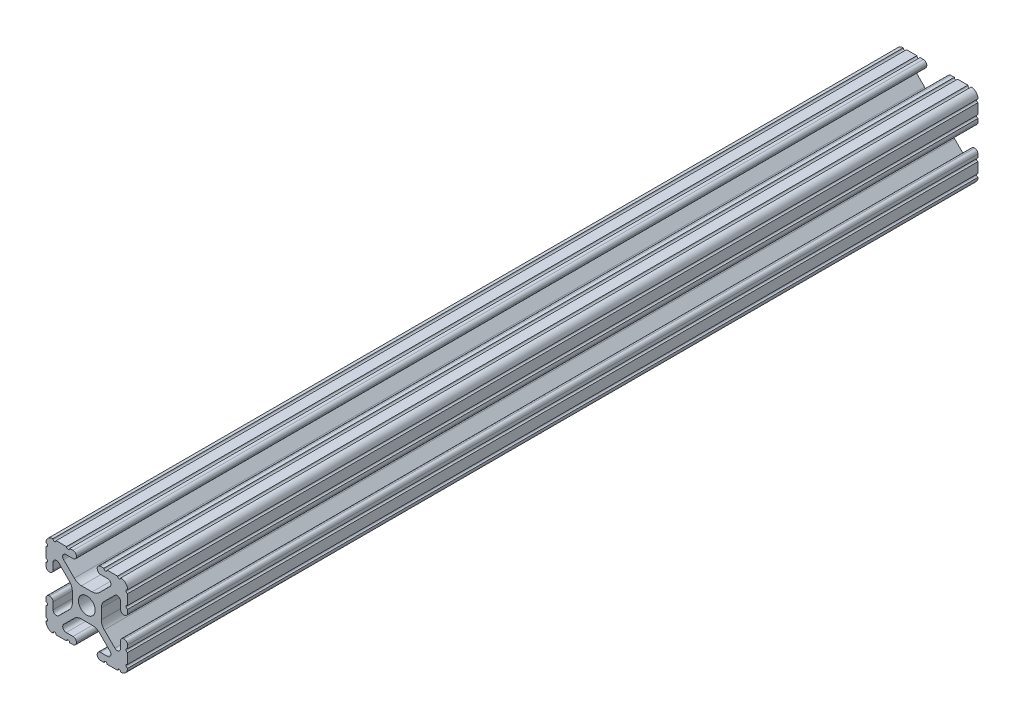
from build123d import *

# Parameters (mm, degrees)
SKETCH1_R               = 2.6035
BOSS_EXTRUDE1_DEPTH     = 457.2
CUT_EXTRUDE2_DEPTH      = 4.318
CUT_EXTRUDE2_DEPTH_BACK = 26.924
SKETCH5_W               = 400.863196081
SKETCH5_H               = 43.327238712
CUT_EXTRUDE3_DEPTH      = 26.4


with BuildPart() as part:
    # Sketch1 → Boss-Extrude1 (new body, symmetric)
    with BuildSketch(Plane.XY):
        with BuildLine():
            Line((-7.179650497, -8.645192506), (-3.952270251, -5.423690499))
            ThreePointArc((-3.952270251, -5.423690499), (-2.922936451, -4.736929036), (-1.709253557, -4.4958))
            Line((-1.709253557, -4.4958), (1.709253557, -4.4958))
            ThreePointArc((1.709253557, -4.4958), (2.922936451, -4.736929036), (3.952270251, -5.423690499))
            Line((3.952270251, -5.423690499), (7.179650497, -8.645192506))
            ThreePointArc((7.179650497, -8.645192506), (7.41473083, -9.822813117), (6.416408329, -10.4902))
            Line((6.416408329, -10.4902), (4.287512407, -10.4902))
            ThreePointArc((4.287512407, -10.4902), (3.54574862, -10.79744862), (3.2385, -11.539212407))
            Line((3.2385, -11.539212407), (3.2385, -11.650987593))
            ThreePointArc((3.2385, -11.650987593), (3.54574862, -12.39275138), (4.287512407, -12.7))
            Line((4.287512407, -12.7), (5.317126718, -12.7))
            ThreePointArc((5.317126718, -12.7), (5.825126718, -12.192), (6.333126718, -12.7))
            Line((6.333126718, -12.7), (9.550443118, -12.7))
            ThreePointArc((9.550443118, -12.7), (10.058366869, -12.192000006), (10.566443095, -12.699847501))
            ThreePointArc((10.566443095, -12.699847501), (12.082537762, -12.08250727), (12.699846982, -10.566399977))
            ThreePointArc((12.699846982, -10.566399977), (12.192000006, -10.058323491), (12.7, -9.5504))
            Line((12.7, -9.5504), (12.7, -6.3330836))
            ThreePointArc((12.7, -6.3330836), (12.192, -5.8250836), (12.7, -5.3170836))
            Line((12.7, -5.3170836), (12.7, -4.287469289))
            ThreePointArc((12.7, -4.287469289), (12.39275138, -3.545705502), (11.650987593, -3.238456882))
            Line((11.650987593, -3.238456882), (11.539212407, -3.238456882))
            ThreePointArc((11.539212407, -3.238456882), (10.79744862, -3.545705502), (10.4902, -4.287469289))
            Line((10.4902, -4.287469289), (10.4902, -6.402089023))
            ThreePointArc((10.4902, -6.402089023), (9.856505071, -7.351067942), (8.737131347, -7.129408934))
            Line((8.737131347, -7.129408934), (5.441005833, -3.840816462))
            ThreePointArc((5.441005833, -3.840816462), (4.750877967, -2.809883091), (4.5085, -1.593185507))
            Line((4.5085, -1.593185507), (4.5085, 1.593185507))
            ThreePointArc((4.5085, 1.593185507), (4.750877967, 2.809883091), (5.441005833, 3.840816462))
            Line((5.441005833, 3.840816462), (8.737131347, 7.129408934))
            ThreePointArc((8.737131347, 7.129408934), (9.856505071, 7.351067942), (10.4902, 6.402089023))
            Line((10.4902, 6.402089023), (10.4902, 4.287469289))
            ThreePointArc((10.4902, 4.287469289), (10.79744862, 3.545705502), (11.539212407, 3.238456882))
            Line((11.539212407, 3.238456882), (11.650987593, 3.238456882))
            ThreePointArc((11.650987593, 3.238456882), (12.39275138, 3.545705502), (12.7, 4.287469289))
            Line((12.7, 4.287469289), (12.7, 5.3170836))
            ThreePointArc((12.7, 5.3170836), (12.192, 5.8250836), (12.7, 6.3330836))
            Line((12.7, 6.3330836), (12.7, 9.5504))
            ThreePointArc((12.7, 9.5504), (12.192000006, 10.058323491), (12.699846982, 10.566399977))
            ThreePointArc((12.699846982, 10.566399977), (12.082537762, 12.08250727), (10.566443095, 12.699847501))
            ThreePointArc((10.566443095, 12.699847501), (10.058366869, 12.192000006), (9.550443118, 12.7))
            Line((9.550443118, 12.7), (6.333126718, 12.7))
            ThreePointArc((6.333126718, 12.7), (5.825126718, 12.192), (5.317126718, 12.7))
            Line((5.317126718, 12.7), (4.287512407, 12.7))
            ThreePointArc((4.287512407, 12.7), (3.54574862, 12.39275138), (3.2385, 11.650987593))
            Line((3.2385, 11.650987593), (3.2385, 11.539212407))
            ThreePointArc((3.2385, 11.539212407), (3.54574862, 10.79744862), (4.287512407, 10.4902))
            Line((4.287512407, 10.4902), (6.476788598, 10.4902))
            ThreePointArc((6.476788598, 10.4902), (7.432222385, 9.85140422), (7.207036008, 8.724370562))
            Line((7.207036008, 8.724370562), (3.898272566, 5.423169045))
            ThreePointArc((3.898272566, 5.423169045), (2.869120213, 4.736787962), (1.655778399, 4.4958))
            Line((1.655778399, 4.4958), (-1.655778399, 4.4958))
            ThreePointArc((-1.655778399, 4.4958), (-2.869120213, 4.736787962), (-3.898272566, 5.423169045))
            Line((-3.898272566, 5.423169045), (-7.207036008, 8.724370562))
            ThreePointArc((-7.207036008, 8.724370562), (-7.432222385, 9.85140422), (-6.476788598, 10.4902))
            Line((-6.476788598, 10.4902), (-4.287512407, 10.4902))
            ThreePointArc((-4.287512407, 10.4902), (-3.54574862, 10.79744862), (-3.2385, 11.539212407))
            Line((-3.2385, 11.539212407), (-3.2385, 11.650987593))
            ThreePointArc((-3.2385, 11.650987593), (-3.54574862, 12.39275138), (-4.287512407, 12.7))
            Line((-4.287512407, 12.7), (-5.317126718, 12.7))
            ThreePointArc((-5.317126718, 12.7), (-5.825126718, 12.192), (-6.333126718, 12.7))
            Line((-6.333126718, 12.7), (-9.550443118, 12.7))
            ThreePointArc((-9.550443118, 12.7), (-10.058366869, 12.192000006), (-10.566443095, 12.699847501))
            ThreePointArc((-10.566443095, 12.699847501), (-12.082537762, 12.08250727), (-12.699846982, 10.566399977))
            ThreePointArc((-12.699846982, 10.566399977), (-12.192000006, 10.058323491), (-12.7, 9.5504))
            Line((-12.7, 9.5504), (-12.7, 6.3330836))
            ThreePointArc((-12.7, 6.3330836), (-12.192, 5.8250836), (-12.7, 5.3170836))
            Line((-12.7, 5.3170836), (-12.7, 4.287469289))
            ThreePointArc((-12.7, 4.287469289), (-12.39275138, 3.545705502), (-11.650987593, 3.238456882))
            Line((-11.650987593, 3.238456882), (-11.539212407, 3.238456882))
            ThreePointArc((-11.539212407, 3.238456882), (-10.79744862, 3.545705502), (-10.4902, 4.287469289))
            Line((-10.4902, 4.287469289), (-10.4902, 6.402089023))
            ThreePointArc((-10.4902, 6.402089023), (-9.856505071, 7.351067942), (-8.737131347, 7.129408934))
            Line((-8.737131347, 7.129408934), (-5.441005833, 3.840816462))
            ThreePointArc((-5.441005833, 3.840816462), (-4.750877967, 2.809883091), (-4.5085, 1.593185507))
            Line((-4.5085, 1.593185507), (-4.5085, -1.593185507))
            ThreePointArc((-4.5085, -1.593185507), (-4.750877967, -2.809883091), (-5.441005833, -3.840816462))
            Line((-5.441005833, -3.840816462), (-8.737131347, -7.129408934))
            ThreePointArc((-8.737131347, -7.129408934), (-9.856505071, -7.351067942), (-10.4902, -6.402089023))
            Line((-10.4902, -6.402089023), (-10.4902, -4.287469289))
            ThreePointArc((-10.4902, -4.287469289), (-10.79744862, -3.545705502), (-11.539212407, -3.238456882))
            Line((-11.539212407, -3.238456882), (-11.650987593, -3.238456882))
            ThreePointArc((-11.650987593, -3.238456882), (-12.39275138, -3.545705502), (-12.7, -4.287469289))
            Line((-12.7, -4.287469289), (-12.7, -5.3170836))
            ThreePointArc((-12.7, -5.3170836), (-12.192, -5.8250836), (-12.7, -6.3330836))
            Line((-12.7, -6.3330836), (-12.7, -9.5504))
            ThreePointArc((-12.7, -9.5504), (-12.192000006, -10.058323491), (-12.699846982, -10.566399977))
            ThreePointArc((-12.699846982, -10.566399977), (-12.082537762, -12.08250727), (-10.566443095, -12.699847501))
            ThreePointArc((-10.566443095, -12.699847501), (-10.058366869, -12.192000006), (-9.550443118, -12.7))
            Line((-9.550443118, -12.7), (-6.333126718, -12.7))
            ThreePointArc((-6.333126718, -12.7), (-5.825126718, -12.192), (-5.317126718, -12.7))
            Line((-5.317126718, -12.7), (-4.287512407, -12.7))
            ThreePointArc((-4.287512407, -12.7), (-3.54574862, -12.39275138), (-3.2385, -11.650987593))
            Line((-3.2385, -11.650987593), (-3.2385, -11.539212407))
            ThreePointArc((-3.2385, -11.539212407), (-3.54574862, -10.79744862), (-4.287512407, -10.4902))
            Line((-4.287512407, -10.4902), (-6.416408329, -10.4902))
            ThreePointArc((-6.416408329, -10.4902), (-7.41473083, -9.822813117), (-7.179650497, -8.645192506))
        make_face()
        Circle(SKETCH1_R, mode=Mode.SUBTRACT)
    extrude(amount=BOSS_EXTRUDE1_DEPTH, both=True)

    # Sketch3 → Cut-Extrude2 (cut, two sides)
    with BuildSketch(Plane.ZY.offset(12.7)) as cut_extrude2_sk:
        Polygon((-203.2, -27.552777595), (-203.2, 21.158109763), (-461.090893327, 21.158109763), (-461.090893327, -25.4), align=None)
    extrude(amount=CUT_EXTRUDE2_DEPTH, mode=Mode.SUBTRACT)
    extrude(cut_extrude2_sk.sketch, amount=-CUT_EXTRUDE2_DEPTH_BACK, mode=Mode.SUBTRACT)

    # Sketch5 → Cut-Extrude3 (cut, through all)
    with BuildSketch(Plane(origin=(12.7, 0, 0), x_dir=(0, 0, -1), z_dir=(1, 0, 0))):
        with Locations((7.887376468, 2.312510515)):
            Rectangle(SKETCH5_W, SKETCH5_H)
    extrude(amount=-CUT_EXTRUDE3_DEPTH, mode=Mode.SUBTRACT)


solid = part.part
